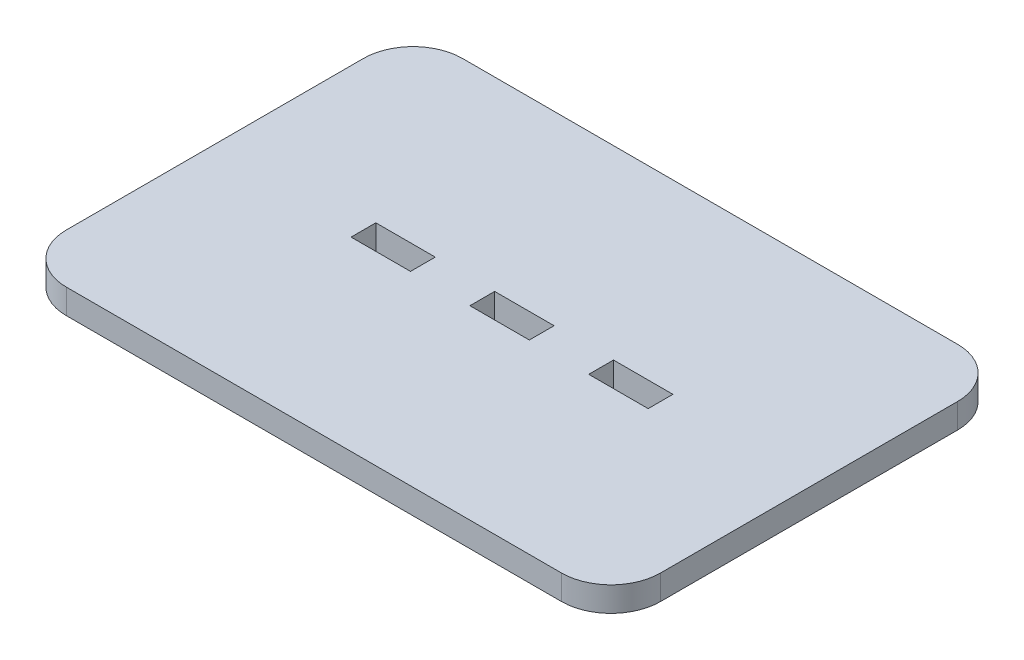
from build123d import *

# Parameters (mm, degrees)
SKETCH1_W           = 12
SKETCH1_H           = 5
BOSS_EXTRUDE1_DEPTH = 5


with BuildPart() as part:
    # Sketch1 → Boss-Extrude1 (new body)
    with BuildSketch(Plane(origin=(0, 0, 0), x_dir=(1, 0, 0), z_dir=(0, 1, 0))):
        with BuildLine():
            Line((-50, 40), (50, 40))
            ThreePointArc((50, 40), (57.071067812, 37.071067812), (60, 30))
            Line((60, 30), (60, -30))
            ThreePointArc((60, -30), (57.071067812, -37.071067812), (50, -40))
            Line((50, -40), (-50, -40))
            ThreePointArc((-50, -40), (-57.071067812, -37.071067812), (-60, -30))
            Line((-60, -30), (-60, 30))
            ThreePointArc((-60, 30), (-57.071067812, 37.071067812), (-50, 40))
        make_face()
        with Locations((-24, 0)):
            Rectangle(SKETCH1_W, SKETCH1_H, mode=Mode.SUBTRACT)
        with Locations((24, 0)):
            Rectangle(SKETCH1_W, SKETCH1_H, mode=Mode.SUBTRACT)
        Rectangle(SKETCH1_W, SKETCH1_H, mode=Mode.SUBTRACT)
    extrude(amount=BOSS_EXTRUDE1_DEPTH)


solid = part.part
